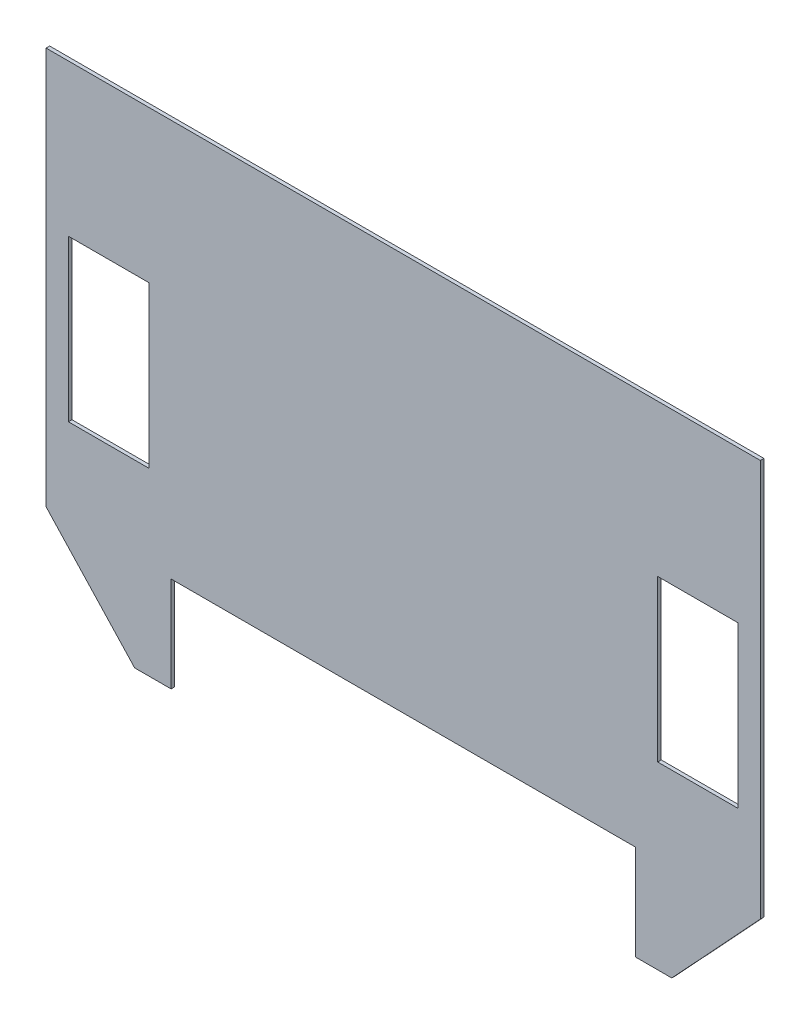
from build123d import *

# Parameters (mm, degrees)
SKETCH1_W           = 45
SKETCH1_H           = 90
BOSS_EXTRUDE1_DEPTH = 2


with BuildPart() as part:
    # Sketch1 → Boss-Extrude1 (new body)
    with BuildSketch(Plane.XY):
        Polygon((200, 0), (-200, 0), (-200, -222.5), (-150.404334867, -275.82), (-130, -275.82), (-130, -222.5), (130, -222.5), (130, -275.82), (150.404334867, -275.82), (200, -222.5), align=None)
        with Locations((-165, -130)):
            Rectangle(SKETCH1_W, SKETCH1_H, mode=Mode.SUBTRACT)
        with Locations((165, -130)):
            Rectangle(SKETCH1_W, SKETCH1_H, mode=Mode.SUBTRACT)
    extrude(amount=BOSS_EXTRUDE1_DEPTH)


solid = part.part
